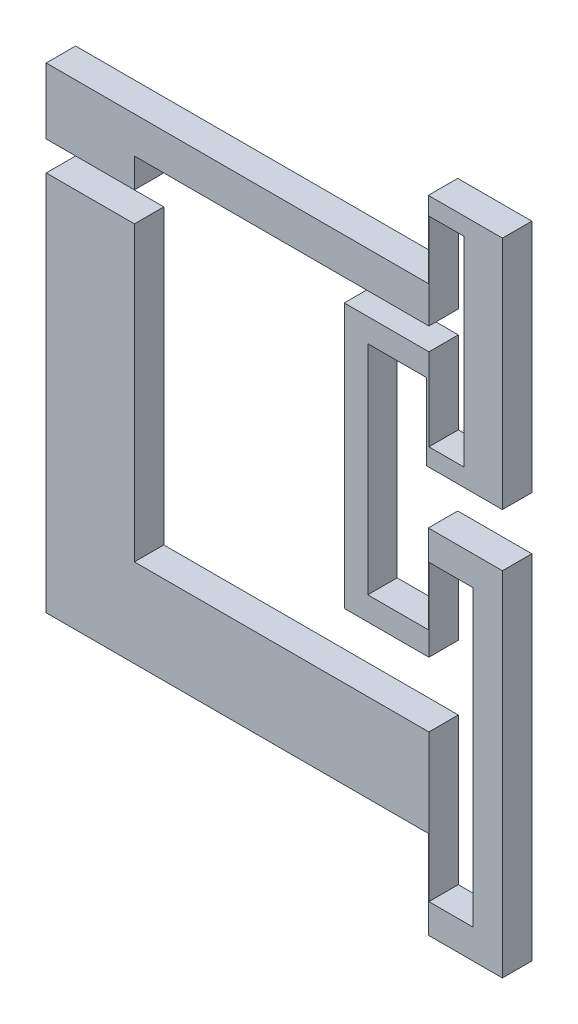
from build123d import *

# Parameters (mm, degrees)
BOSS_EXTRUDE1_DEPTH = 5


with BuildPart() as part:
    # Sketch1 → Boss-Extrude1 (new body)
    with BuildSketch(Plane.XY):
        Polygon((0, 0), (0, 64.8), (15, 64.8), (15, 15), (65.1, 15), (65.1, -10), (72.6, -10), (72.6, 40), (65.1, 40), (65.1, 35), (65.1, 26), (50.7, 26), (50.7, 71), (65.1, 71), (65.1, 67), (65.1, 57), (71.1, 57), (71.1, 91), (65.1, 91), (65.1, 81), (65.1, 74.8), (15, 74.8), (15, 69.8), (0, 69.8), (0, 81), (65, 81), (65, 94), (77.6, 94), (77.6, 54), (64.7, 54), (64.7, 67), (54.7, 67), (54.7, 30), (65, 30), (65, 45), (77.6, 45), (77.6, -15), (65, -15), (65, -10), (65, 0), align=None)
    extrude(amount=BOSS_EXTRUDE1_DEPTH)


solid = part.part
